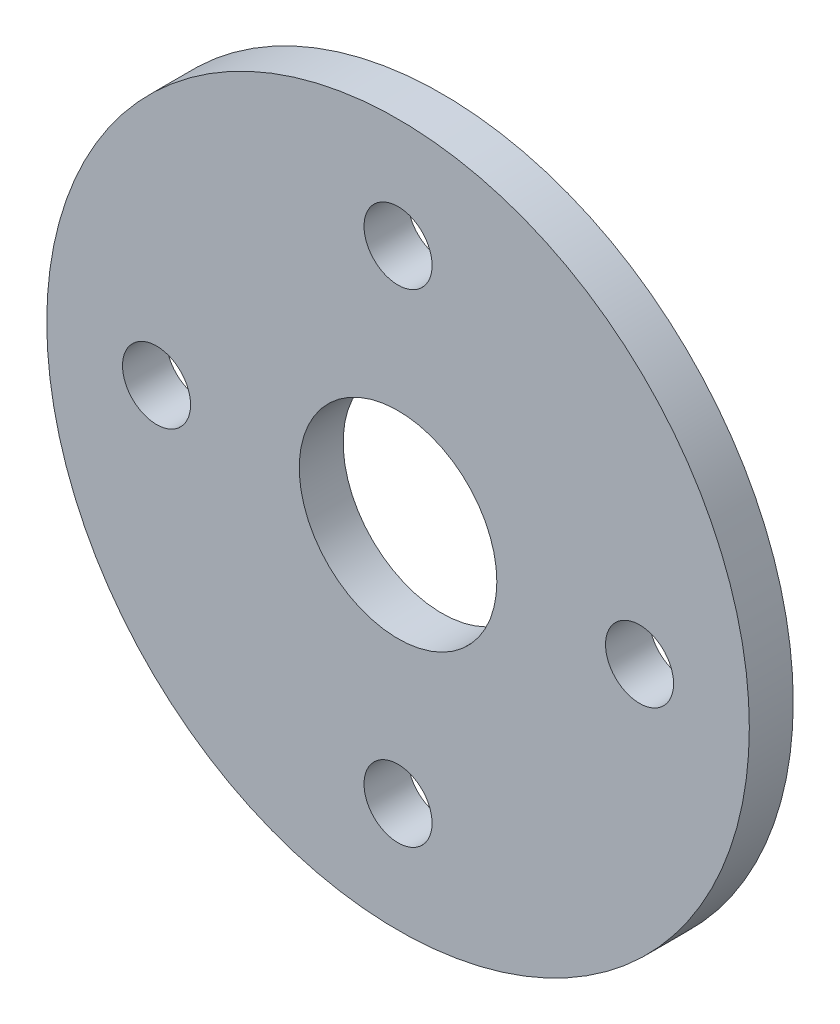
from build123d import *

# Parameters (mm, degrees)
SKETCH1_R           = 16
SKETCH1_R_2         = 4.5
SKETCH1_R_3         = 1.55
BOSS_EXTRUDE1_DEPTH = 2


with BuildPart() as part:
    # Sketch1 → Boss-Extrude1 (new body)
    with BuildSketch(Plane.XY):
        Circle(SKETCH1_R)
        Circle(SKETCH1_R_2, mode=Mode.SUBTRACT)
        with Locations((0, 11)):
            Circle(SKETCH1_R_3, mode=Mode.SUBTRACT)
        with Locations((11, 0)):
            Circle(SKETCH1_R_3, mode=Mode.SUBTRACT)
        with Locations((0, -11)):
            Circle(SKETCH1_R_3, mode=Mode.SUBTRACT)
        with Locations((-11, 0)):
            Circle(SKETCH1_R_3, mode=Mode.SUBTRACT)
    extrude(amount=BOSS_EXTRUDE1_DEPTH)


solid = part.part
